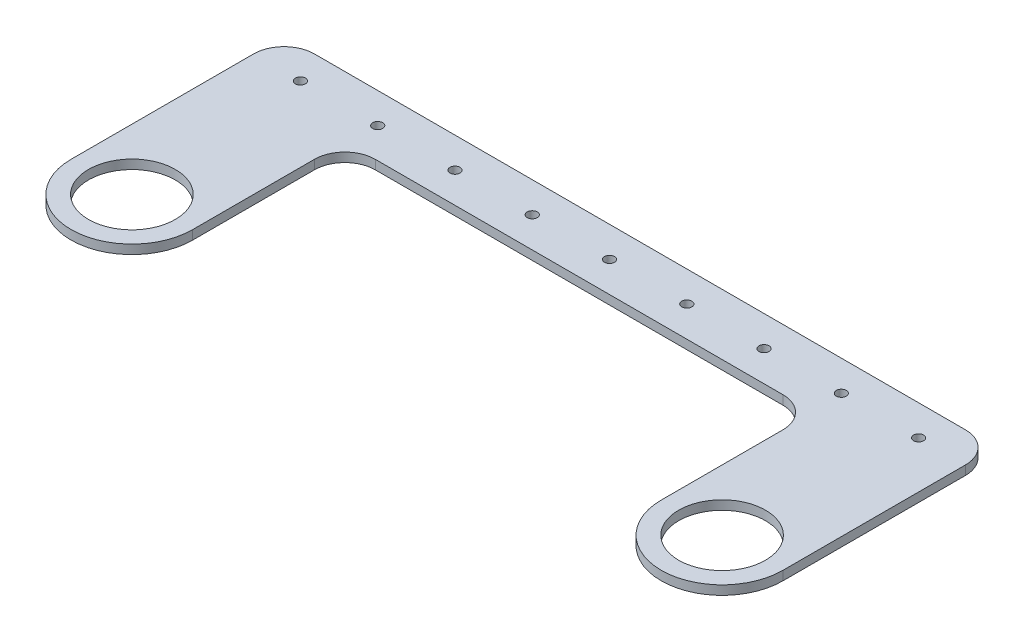
from build123d import *

# Parameters (mm, degrees)
SKETCH1_R           = 1.65
SKETCH1_R_2         = 14.26
BOSS_EXTRUDE1_DEPTH = 3
FILLET1_R           = 10


with BuildPart() as part:
    # Sketch1 → Boss-Extrude1 (new body)
    with BuildSketch(Plane(origin=(0, 0, 0), x_dir=(1, 0, 0), z_dir=(0, 1, 0))):
        with BuildLine():
            Line((-77, -10), (77, -10))
            Line((77, -10), (77, -60))
            ThreePointArc((77, -60), (97, -80), (117, -60))
            Line((117, -60), (117, 10))
            Line((117, 10), (-117, 10))
            Line((-117, 10), (-117, -60))
            ThreePointArc((-117, -60), (-97, -80), (-77, -60))
            Line((-77, -60), (-77, -10))
        make_face()
        with Locations((76.2, 0)):
            Circle(SKETCH1_R, mode=Mode.SUBTRACT)
        with Locations((-76.2, 0)):
            Circle(SKETCH1_R, mode=Mode.SUBTRACT)
        with Locations((-50.8, 0)):
            Circle(SKETCH1_R, mode=Mode.SUBTRACT)
        with Locations((-25.4, 0)):
            Circle(SKETCH1_R, mode=Mode.SUBTRACT)
        Circle(SKETCH1_R, mode=Mode.SUBTRACT)
        with Locations((25.4, 0)):
            Circle(SKETCH1_R, mode=Mode.SUBTRACT)
        with Locations((50.8, 0)):
            Circle(SKETCH1_R, mode=Mode.SUBTRACT)
        with Locations((-101.6, 0)):
            Circle(SKETCH1_R, mode=Mode.SUBTRACT)
        with Locations((101.6, 0)):
            Circle(SKETCH1_R, mode=Mode.SUBTRACT)
        with Locations((-97, -60)):
            Circle(SKETCH1_R_2, mode=Mode.SUBTRACT)
        with Locations((97, -60)):
            Circle(SKETCH1_R_2, mode=Mode.SUBTRACT)
    extrude(amount=BOSS_EXTRUDE1_DEPTH)

    # Fillet1
    fillet1_edges = [part.edges().sort_by_distance(p)[0] for p in [
        (-77, 1.5, 10),
        (-117, 1.5, -10),
        (117, 1.5, -10),
        (77, 1.5, 10),
    ]]
    fillet(fillet1_edges, radius=FILLET1_R)


solid = part.part
